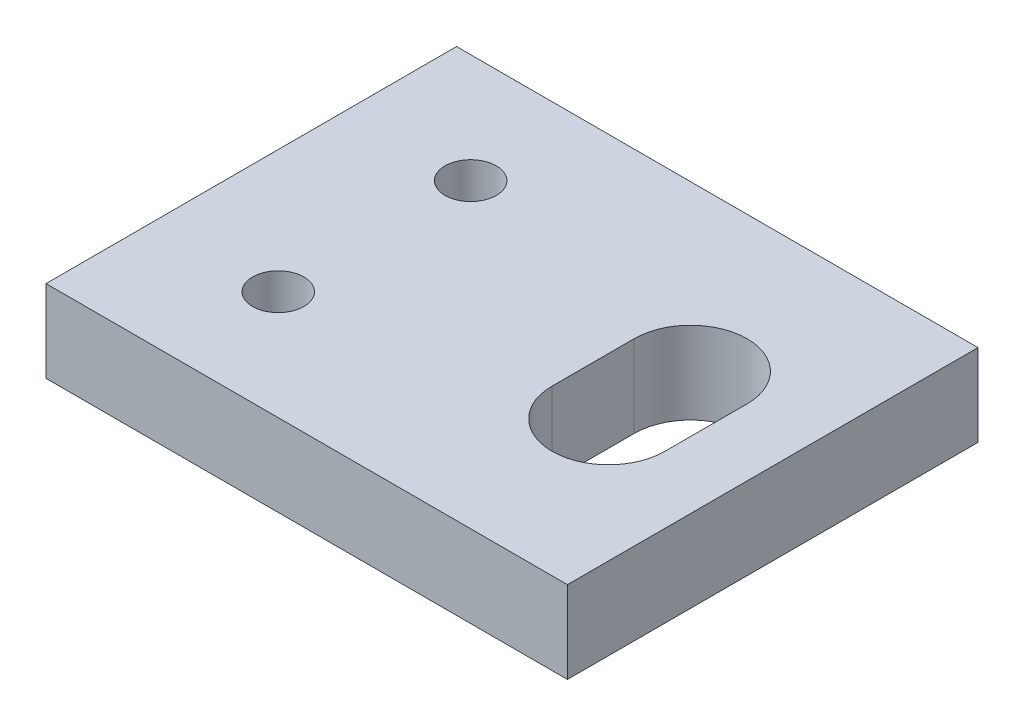
from build123d import *

# Parameters (mm, degrees)
SKETCH1_W           = 25.4
SKETCH1_H           = 20
SKETCH1_R           = 1.25
BOSS_EXTRUDE1_DEPTH = 4


with BuildPart() as part:
    # Sketch1 → Boss-Extrude1 (new body)
    with BuildSketch(Plane(origin=(0, 4, 0), x_dir=(1, 0, 0), z_dir=(0, 1, 0))):
        with Locations((12.7, -10)):
            Rectangle(SKETCH1_W, SKETCH1_H)
        with Locations((6, -14.686)):
            Circle(SKETCH1_R, mode=Mode.SUBTRACT)
        with Locations((6, -5.314)):
            Circle(SKETCH1_R, mode=Mode.SUBTRACT)
        with BuildLine():
            Line((16.65, -12), (16.65, -8))
            ThreePointArc((16.65, -8), (19.4, -5.25), (22.15, -8))
            Line((22.15, -8), (22.15, -12))
            ThreePointArc((22.15, -12), (19.4, -14.75), (16.65, -12))
        make_face(mode=Mode.SUBTRACT)
    extrude(amount=-BOSS_EXTRUDE1_DEPTH)


solid = part.part
